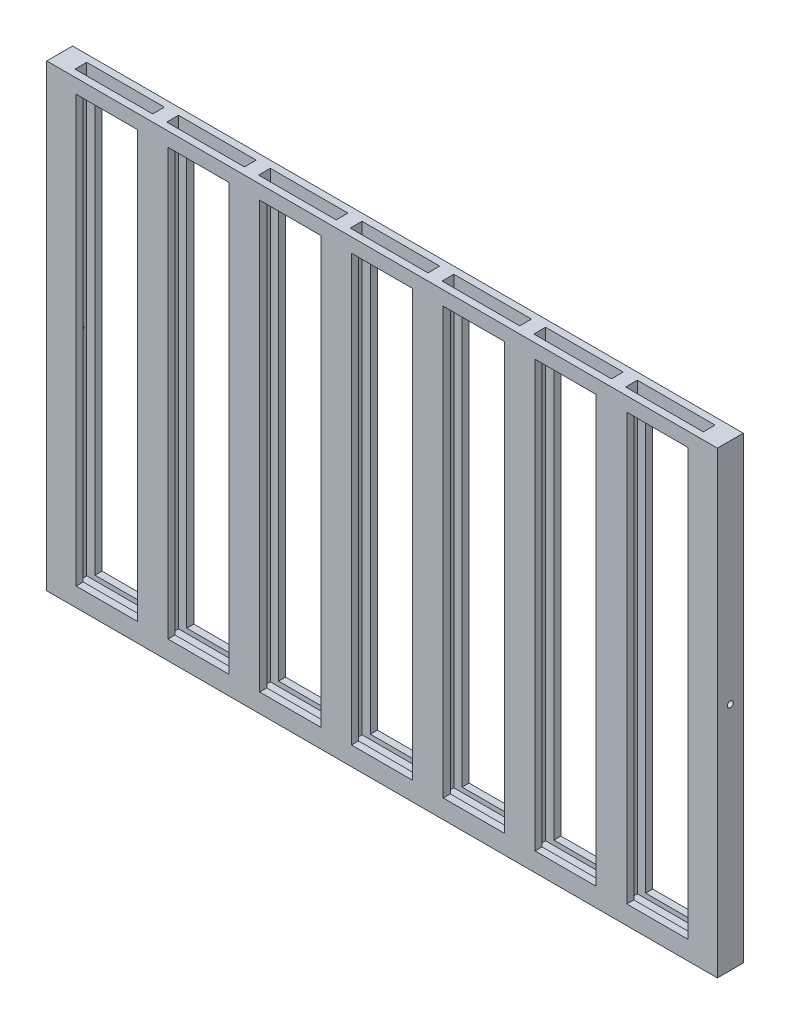
from build123d import *

# Parameters (mm, degrees)
SKETCH2_W           = 570
SKETCH2_H           = 390
BOSS_EXTRUDE1_DEPTH = 22
SKETCH4_W           = 534
SKETCH4_H           = 10
CUT_EXTRUDE1_DEPTH  = 378
SKETCH5_W           = 12
SKETCH5_H           = 10
BOSS_EXTRUDE2_DEPTH = 378
CUT_EXTRUDE3_REACH  = 572
SKETCH6_R           = 2.5
CUT_EXTRUDE4_REACH  = 572
SKETCH7_R           = 2.5
SKETCH3_W           = 52
SKETCH3_H           = 362
CUT_EXTRUDE5_DEPTH  = 23


with BuildPart() as part:
    # Sketch2 → Boss-Extrude1 (new body)
    with BuildSketch(Plane.XY):
        Rectangle(SKETCH2_W, SKETCH2_H)
    extrude(amount=BOSS_EXTRUDE1_DEPTH)

    # Sketch4 → Cut-Extrude1 (cut)
    with BuildSketch(Plane(origin=(0, 195, 0), x_dir=(1, 0, 0), z_dir=(0, 1, 0))):
        with Locations((0, -11)):
            Rectangle(SKETCH4_W, SKETCH4_H)
    extrude(amount=-CUT_EXTRUDE1_DEPTH, mode=Mode.SUBTRACT)

    # Sketch5 → Boss-Extrude2 (add)
    with BuildSketch(Plane(origin=(0, 195, 0), x_dir=(1, 0, 0), z_dir=(0, 1, 0))):
        with Locations((195, -11)):
            Rectangle(SKETCH5_W, SKETCH5_H)
        with Locations((117, -11)):
            Rectangle(SKETCH5_W, SKETCH5_H)
        with Locations((39, -11)):
            Rectangle(SKETCH5_W, SKETCH5_H)
        with Locations((-39, -11)):
            Rectangle(SKETCH5_W, SKETCH5_H)
        with Locations((-117, -11)):
            Rectangle(SKETCH5_W, SKETCH5_H)
        with Locations((-195, -11)):
            Rectangle(SKETCH5_W, SKETCH5_H)
    extrude(amount=-BOSS_EXTRUDE2_DEPTH)

    # Sketch6 → Cut-Extrude3 (cut, up to next)
    with BuildSketch(Plane.ZY.offset(285), mode=Mode.PRIVATE) as cut_extrude3_sk1:
        with Locations((11, 1)):
            Circle(SKETCH6_R)
    cut_extrude3_tool1 = extrude(cut_extrude3_sk1.sketch, amount=-CUT_EXTRUDE3_REACH, mode=Mode.PRIVATE) & part.part
    add(cut_extrude3_tool1.solids().sort_by_distance((-285, 1, 11))[0], mode=Mode.SUBTRACT)

    # Sketch7 → Cut-Extrude4 (cut, up to next)
    with BuildSketch(Plane(origin=(285, 0, 0), x_dir=(0, 0, -1), z_dir=(1, 0, 0)), mode=Mode.PRIVATE) as cut_extrude4_sk1:
        with Locations((-11, 1)):
            Circle(SKETCH7_R)
    cut_extrude4_tool1 = extrude(cut_extrude4_sk1.sketch, amount=-CUT_EXTRUDE4_REACH, mode=Mode.PRIVATE) & part.part
    add(cut_extrude4_tool1.solids().sort_by_distance((285, 1, 11))[0], mode=Mode.SUBTRACT)

    # Sketch3 → Cut-Extrude5 (cut, through all)
    with BuildSketch(Plane(origin=(0, 0, 0), x_dir=(-1, 0, 0), z_dir=(0, 0, -1))):
        with Locations((-156, 2)):
            Rectangle(SKETCH3_W, SKETCH3_H)
        with Locations((-234, 2)):
            Rectangle(SKETCH3_W, SKETCH3_H)
        with Locations((-78, 2)):
            Rectangle(SKETCH3_W, SKETCH3_H)
        with Locations((0, 2)):
            Rectangle(SKETCH3_W, SKETCH3_H)
        with Locations((78, 2)):
            Rectangle(SKETCH3_W, SKETCH3_H)
        with Locations((156, 2)):
            Rectangle(SKETCH3_W, SKETCH3_H)
        with Locations((234, 2)):
            Rectangle(SKETCH3_W, SKETCH3_H)
    extrude(amount=-CUT_EXTRUDE5_DEPTH, mode=Mode.SUBTRACT)


solid = part.part
